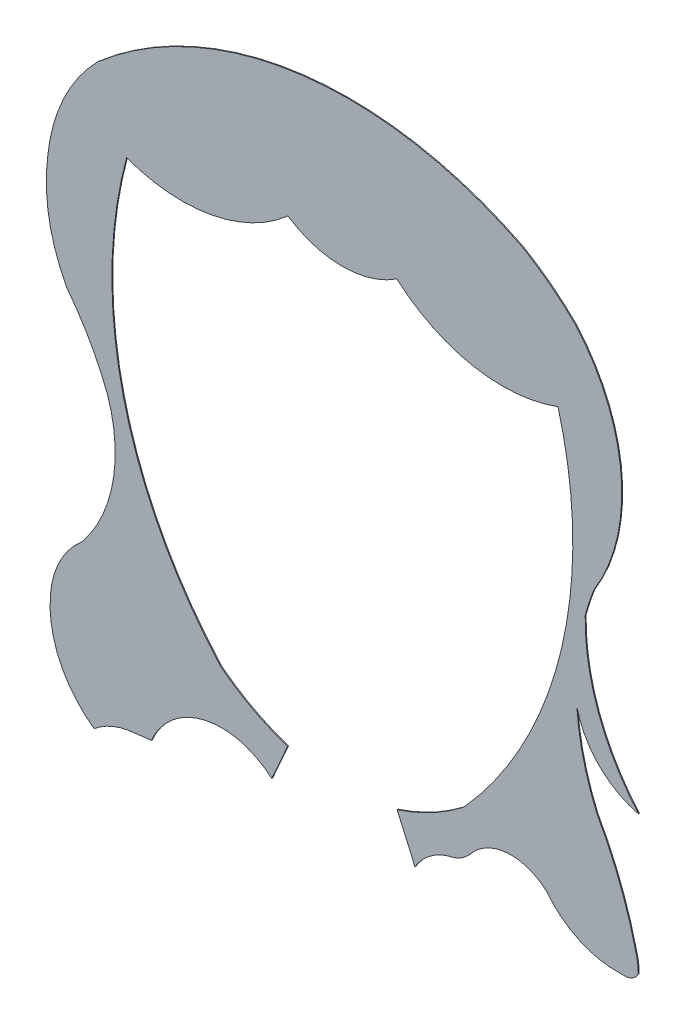
from build123d import *

# Parameters (mm, degrees)
SALIENTE_EXTRUIR1_DEPTH = 0.1


with BuildPart() as part:
    # Model → Saliente-Extruir1 (new body)
    with BuildSketch(Plane.XY):
        with BuildLine():
            Line((7.842607398, 33.951363828), (9.579734894, 37.856921812))
            ThreePointArc((9.579734894, 37.856921812), (5.853816343, 39.435481261), (2.446469011, 41.618209633))
            ThreePointArc((2.446469011, 41.618209633), (2.30530398, 41.73720898), (2.175714205, 41.868719058))
            ThreePointArc((2.175714205, 41.868719058), (-8.403464325, 62.063986958), (-8.03987526, 84.859505528))
            ThreePointArc((-8.03987526, 84.859505528), (1.236190849, 84.069577534), (9.603788078, 88.150350168))
            ThreePointArc((9.603788078, 88.150350168), (15.569580386, 86.351015884), (21.535340373, 88.150457325))
            ThreePointArc((21.535340373, 88.150457325), (29.9030109, 84.069834991), (39.179062819, 84.859929602))
            ThreePointArc((39.179062819, 84.859929602), (39.545951554, 62.067945489), (28.972930685, 41.873382438))
            ThreePointArc((28.972930685, 41.873382438), (28.843386689, 41.741827264), (28.702263084, 41.622778791))
            ThreePointArc((28.702263084, 41.622778791), (25.291019086, 39.436407853), (21.560299513, 37.855732375))
            Line((21.560299513, 37.855732375), (23.296856275, 33.951104051))
            ThreePointArc((23.296856275, 33.951104051), (23.379782362, 33.667159579), (23.503682681, 33.398552226))
            ThreePointArc((23.503682681, 33.398552226), (24.91201243, 35.055347002), (26.795735375, 36.141601796))
            ThreePointArc((26.795735375, 36.141601796), (27.061156988, 36.22854536), (27.331998678, 36.296755293))
            ThreePointArc((27.331998678, 36.296755293), (28.581463341, 36.797016912), (29.594274303, 37.683378907))
            ThreePointArc((29.594274303, 37.683378907), (33.634090695, 39.784233724), (37.930992822, 38.277469126))
            ThreePointArc((37.930992822, 38.277469126), (41.505714026, 35.445010711), (45.978885302, 34.554959535))
            ThreePointArc((45.978885302, 34.554959535), (46.208146888, 34.559844902), (46.437427714, 34.555966165))
            ThreePointArc((46.437427714, 34.555966165), (47.345458783, 34.798460155), (47.962246093, 35.507612586))
            ThreePointArc((47.962246093, 35.507612586), (47.867291161, 36.636427891), (47.611593039, 37.739994337))
            ThreePointArc((47.611593039, 37.739994337), (45.887992379, 43.222004619), (43.431064267, 48.416880961))
            ThreePointArc((43.431064267, 48.416880961), (41.946296228, 52.847104425), (41.234230474, 57.46493708))
            ThreePointArc((41.234230474, 57.46493708), (43.653110533, 53.102823777), (48.0017493, 50.65980227))
            ThreePointArc((48.0017493, 50.65980227), (43.593122133, 58.078880454), (42.149031339, 66.587306652))
            ThreePointArc((42.149031339, 66.587306652), (42.59469449, 68.050991275), (43.121201087, 69.487577202))
            ThreePointArc((43.121201087, 69.487577202), (46.085206987, 81.850895157), (41.113090097, 93.551964146))
            ThreePointArc((41.113090097, 93.551964146), (38.356950801, 95.965555009), (35.322319177, 98.018049973))
            ThreePointArc((35.322319177, 98.018049973), (11.172182801, 102.279245092), (-11.242648027, 92.331268928))
            ThreePointArc((-11.242648027, 92.331268928), (-14.949595702, 86.979124351), (-16.674221293, 80.701180482))
            ThreePointArc((-16.674221293, 80.701180482), (-16.531478417, 74.824409953), (-14.601116723, 69.271887003))
            ThreePointArc((-14.601116723, 69.271887003), (-12.073727961, 65.477087664), (-10.129040046, 61.353207829))
            ThreePointArc((-10.129040046, 61.353207829), (-9.555595879, 53.303802947), (-12.946389483, 45.980943128))
            ThreePointArc((-12.946389483, 45.980943128), (-15.354439926, 42.946547728), (-16.383842014, 39.212033874))
            ThreePointArc((-16.383842014, 39.212033874), (-15.350532825, 33.44879775), (-11.593101389, 28.958327007))
            ThreePointArc((-11.593101389, 28.958327007), (-9.872267141, 30.049029711), (-7.929133035, 30.661510518))
            Line((-7.929133035, 30.661510518), (-5.334790759, 30.979264145))
            ThreePointArc((-5.334790759, 30.979264145), (0.499105837, 35.811881702), (7.842607398, 33.951363828))
        make_face()
    extrude(amount=SALIENTE_EXTRUIR1_DEPTH)


solid = part.part
